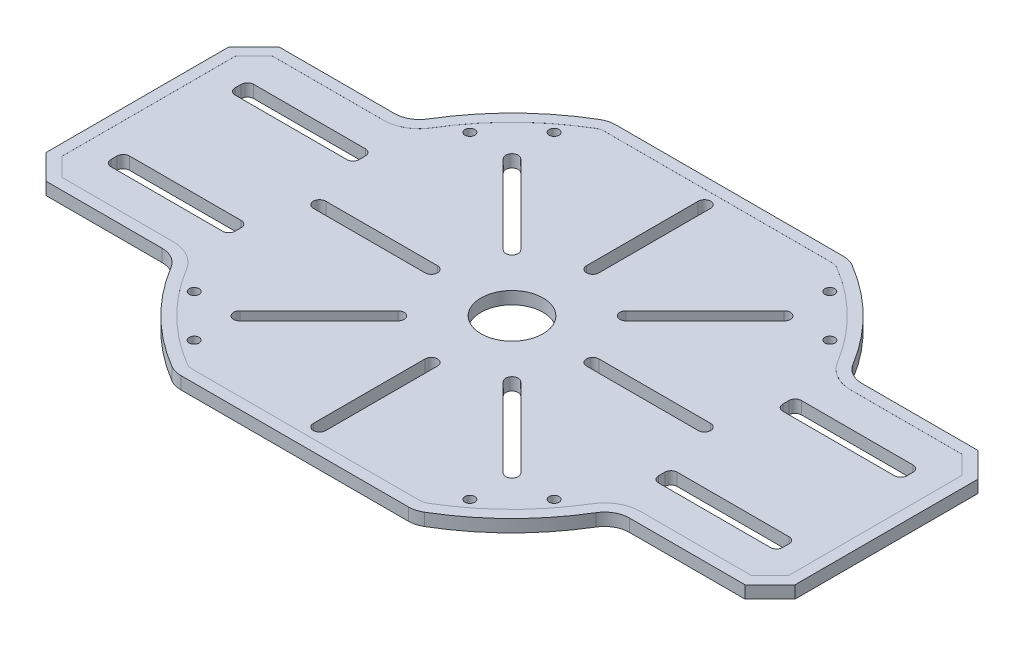
from build123d import *

# Parameters (mm, degrees)
SKETCH1_R           = 6.35
SKETCH1_R_2         = 1.016
SKETCH1_R_3         = 0.080960088
BOSS_EXTRUDE1_DEPTH = 2.54
CUT_EXTRUDE1_DEPTH  = 2.54
CUT_EXTRUDE2_DEPTH  = 2.54
BOSS_EXTRUDE2_DEPTH = 0.01


with BuildPart() as part:
    # Sketch1 → Boss-Extrude1 (new body)
    with BuildSketch(Plane(origin=(0, 0, 0), x_dir=(1, 0, 0), z_dir=(0, 1, 0))):
        with BuildLine():
            Line((-23.244816627, 44.45), (23.244816627, 44.45))
            ThreePointArc((23.244816627, 44.45), (24.583514169, 44.270437622), (25.827574029, 43.744444444))
            ThreePointArc((25.827574029, 43.744444444), (35.740062311, 36.101079569), (43.482663438, 26.265909091))
            ThreePointArc((43.482663438, 26.265909091), (45.334600658, 24.468164919), (47.830929781, 23.8125))
            Line((47.830929781, 23.8125), (71.516875, 23.8125))
            Line((71.516875, 23.8125), (76.596875, 18.7325))
            Line((76.596875, 18.7325), (76.596875, -18.7325))
            Line((76.596875, -18.7325), (71.516875, -23.8125))
            Line((71.516875, -23.8125), (47.830929781, -23.8125))
            ThreePointArc((47.830929781, -23.8125), (45.334600658, -24.468164919), (43.482663438, -26.265909091))
            ThreePointArc((43.482663438, -26.265909091), (35.740062311, -36.101079569), (25.827574029, -43.744444444))
            ThreePointArc((25.827574029, -43.744444444), (24.583514169, -44.270437622), (23.244816627, -44.45))
            Line((23.244816627, -44.45), (-23.244816627, -44.45))
            ThreePointArc((-23.244816627, -44.45), (-24.583514169, -44.270437622), (-25.827574029, -43.744444444))
            ThreePointArc((-25.827574029, -43.744444444), (-35.740062311, -36.101079569), (-43.482663438, -26.265909091))
            ThreePointArc((-43.482663438, -26.265909091), (-45.334600658, -24.468164919), (-47.830929781, -23.8125))
            Line((-47.830929781, -23.8125), (-71.516875, -23.8125))
            Line((-71.516875, -23.8125), (-76.596875, -18.7325))
            Line((-76.596875, -18.7325), (-76.596875, 18.7325))
            Line((-76.596875, 18.7325), (-71.516875, 23.8125))
            Line((-71.516875, 23.8125), (-47.830929781, 23.8125))
            ThreePointArc((-47.830929781, 23.8125), (-45.334600658, 24.468164919), (-43.482663438, 26.265909091))
            ThreePointArc((-43.482663438, 26.265909091), (-35.740062311, 36.101079569), (-25.827574029, 43.744444444))
            ThreePointArc((-25.827574029, 43.744444444), (-24.583514169, 44.270437622), (-23.244816627, 44.45))
        make_face()
        Circle(SKETCH1_R, mode=Mode.SUBTRACT)
        with Locations((36.819050096, 28.19800422)):
            Circle(SKETCH1_R_2, mode=Mode.SUBTRACT)
        with Locations((28.19800422, 36.819050096)):
            Circle(SKETCH1_R_2, mode=Mode.SUBTRACT)
        with Locations((26.671582547, 26.671582547)):
            Circle(SKETCH1_R_3, mode=Mode.SUBTRACT)
        with Locations((26.671582547, -26.671582547)):
            Circle(SKETCH1_R_3, mode=Mode.SUBTRACT)
        with Locations((36.819050096, -28.19800422)):
            Circle(SKETCH1_R_2, mode=Mode.SUBTRACT)
        with Locations((28.19800422, -36.819050096)):
            Circle(SKETCH1_R_2, mode=Mode.SUBTRACT)
        with Locations((-26.671582547, -26.671582547)):
            Circle(SKETCH1_R_3, mode=Mode.SUBTRACT)
        with Locations((-28.19800422, -36.819050096)):
            Circle(SKETCH1_R_2, mode=Mode.SUBTRACT)
        with Locations((-36.819050096, -28.19800422)):
            Circle(SKETCH1_R_2, mode=Mode.SUBTRACT)
        with Locations((-26.671582547, 26.671582547)):
            Circle(SKETCH1_R_3, mode=Mode.SUBTRACT)
        with Locations((-36.819050096, 28.19800422)):
            Circle(SKETCH1_R_2, mode=Mode.SUBTRACT)
        with Locations((-28.19800422, 36.819050096)):
            Circle(SKETCH1_R_2, mode=Mode.SUBTRACT)
    extrude(amount=BOSS_EXTRUDE1_DEPTH)

    # Sketch3 → Cut-Extrude1 (cut)
    with BuildSketch(Plane(origin=(0, 2.54, 0), x_dir=(1, 0, 0), z_dir=(0, 1, 0))):
        with BuildLine():
            Line((10.776307345, 12.572358569), (26.940768363, 28.736819587))
            ThreePointArc((26.940768363, 28.736819587), (28.736819587, 28.736819587), (28.736819587, 26.940768363))
            Line((28.736819587, 26.940768363), (12.572358569, 10.776307345))
            ThreePointArc((12.572358569, 10.776307345), (10.776307345, 10.776307345), (10.776307345, 12.572358569))
        make_face()
        with BuildLine():
            Line((16.51, -1.27), (39.37, -1.27))
            ThreePointArc((39.37, -1.27), (40.64, 0), (39.37, 1.27))
            Line((39.37, 1.27), (16.51, 1.27))
            ThreePointArc((16.51, 1.27), (15.24, 0), (16.51, -1.27))
        make_face()
        with BuildLine():
            Line((10.776307345, -12.572358569), (26.940768363, -28.736819587))
            ThreePointArc((26.940768363, -28.736819587), (28.736819587, -28.736819587), (28.736819587, -26.940768363))
            Line((28.736819587, -26.940768363), (12.572358569, -10.776307345))
            ThreePointArc((12.572358569, -10.776307345), (10.776307345, -10.776307345), (10.776307345, -12.572358569))
        make_face()
        with BuildLine():
            Line((-1.27, -16.51), (-1.27, -39.37))
            ThreePointArc((-1.27, -39.37), (0, -40.64), (1.27, -39.37))
            Line((1.27, -39.37), (1.27, -16.51))
            ThreePointArc((1.27, -16.51), (0, -15.24), (-1.27, -16.51))
        make_face()
        with BuildLine():
            Line((-12.572358569, -10.776307345), (-28.736819587, -26.940768363))
            ThreePointArc((-28.736819587, -26.940768363), (-28.736819587, -28.736819587), (-26.940768363, -28.736819587))
            Line((-26.940768363, -28.736819587), (-10.776307345, -12.572358569))
            ThreePointArc((-10.776307345, -12.572358569), (-10.776307345, -10.776307345), (-12.572358569, -10.776307345))
        make_face()
        with BuildLine():
            Line((-16.51, 1.27), (-39.37, 1.27))
            ThreePointArc((-39.37, 1.27), (-40.64, 0), (-39.37, -1.27))
            Line((-39.37, -1.27), (-16.51, -1.27))
            ThreePointArc((-16.51, -1.27), (-15.24, 0), (-16.51, 1.27))
        make_face()
        with BuildLine():
            Line((-10.776307345, 12.572358569), (-26.940768363, 28.736819587))
            ThreePointArc((-26.940768363, 28.736819587), (-28.736819587, 28.736819587), (-28.736819587, 26.940768363))
            Line((-28.736819587, 26.940768363), (-12.572358569, 10.776307345))
            ThreePointArc((-12.572358569, 10.776307345), (-10.776307345, 10.776307345), (-10.776307345, 12.572358569))
        make_face()
        with BuildLine():
            Line((1.27, 16.51), (1.27, 39.37))
            ThreePointArc((1.27, 39.37), (0, 40.64), (-1.27, 39.37))
            Line((-1.27, 39.37), (-1.27, 16.51))
            ThreePointArc((-1.27, 16.51), (0, 15.24), (1.27, 16.51))
        make_face()
    extrude(amount=-CUT_EXTRUDE1_DEPTH, mode=Mode.SUBTRACT)

    # Sketch4 → Cut-Extrude2 (cut)
    with BuildSketch(Plane(origin=(0, 2.54, 0), x_dir=(1, 0, 0), z_dir=(0, 1, 0))):
        with BuildLine():
            Line((44.592875, 14.605), (67.452875, 14.605))
            ThreePointArc((67.452875, 14.605), (68.350900612, 14.233025612), (68.722875, 13.335))
            Line((68.722875, 13.335), (68.722875, 12.065))
            ThreePointArc((68.722875, 12.065), (68.350900612, 11.166974388), (67.452875, 10.795))
            Line((67.452875, 10.795), (44.592875, 10.795))
            ThreePointArc((44.592875, 10.795), (43.694849388, 11.166974388), (43.322875, 12.065))
            Line((43.322875, 12.065), (43.322875, 13.335))
            ThreePointArc((43.322875, 13.335), (43.694849388, 14.233025612), (44.592875, 14.605))
        make_face()
        with BuildLine():
            Line((68.722875, -13.335), (68.722875, -12.065))
            ThreePointArc((68.722875, -12.065), (68.350900612, -11.166974388), (67.452875, -10.795))
            Line((67.452875, -10.795), (44.592875, -10.795))
            ThreePointArc((44.592875, -10.795), (43.694849388, -11.166974388), (43.322875, -12.065))
            Line((43.322875, -12.065), (43.322875, -13.335))
            ThreePointArc((43.322875, -13.335), (43.694849388, -14.233025612), (44.592875, -14.605))
            Line((44.592875, -14.605), (67.452875, -14.605))
            ThreePointArc((67.452875, -14.605), (68.350900612, -14.233025612), (68.722875, -13.335))
        make_face()
        with BuildLine():
            Line((-44.592875, -14.605), (-67.452875, -14.605))
            ThreePointArc((-67.452875, -14.605), (-68.350900612, -14.233025612), (-68.722875, -13.335))
            Line((-68.722875, -13.335), (-68.722875, -12.065))
            ThreePointArc((-68.722875, -12.065), (-68.350900612, -11.166974388), (-67.452875, -10.795))
            Line((-67.452875, -10.795), (-44.592875, -10.795))
            ThreePointArc((-44.592875, -10.795), (-43.694849388, -11.166974388), (-43.322875, -12.065))
            Line((-43.322875, -12.065), (-43.322875, -13.335))
            ThreePointArc((-43.322875, -13.335), (-43.694849388, -14.233025612), (-44.592875, -14.605))
        make_face()
        with BuildLine():
            Line((-68.722875, 13.335), (-68.722875, 12.065))
            ThreePointArc((-68.722875, 12.065), (-68.350900612, 11.166974388), (-67.452875, 10.795))
            Line((-67.452875, 10.795), (-44.592875, 10.795))
            ThreePointArc((-44.592875, 10.795), (-43.694849388, 11.166974388), (-43.322875, 12.065))
            Line((-43.322875, 12.065), (-43.322875, 13.335))
            ThreePointArc((-43.322875, 13.335), (-43.694849388, 14.233025612), (-44.592875, 14.605))
            Line((-44.592875, 14.605), (-67.452875, 14.605))
            ThreePointArc((-67.452875, 14.605), (-68.350900612, 14.233025612), (-68.722875, 13.335))
        make_face()
    extrude(amount=-CUT_EXTRUDE2_DEPTH, mode=Mode.SUBTRACT)

    # Sketch8 → Boss-Extrude2 (add)
    with BuildSketch(Plane(origin=(0, 2.54, 0), x_dir=(1, 0, 0), z_dir=(0, 1, 0))):
        with BuildLine():
            Line((47.830929781, -23.8125), (71.516875, -23.8125))
            Line((71.516875, -23.8125), (76.596875, -18.7325))
            Line((76.596875, -18.7325), (76.596875, 18.7325))
            Line((76.596875, 18.7325), (71.516875, 23.8125))
            Line((71.516875, 23.8125), (47.830929781, 23.8125))
            ThreePointArc((47.830929781, 23.8125), (45.334600658, 24.468164919), (43.482663438, 26.265909091))
            ThreePointArc((43.482663438, 26.265909091), (35.740062311, 36.101079569), (25.827574029, 43.744444444))
            ThreePointArc((25.827574029, 43.744444444), (24.583514169, 44.270437622), (23.244816627, 44.45))
            Line((23.244816627, 44.45), (-23.244816627, 44.45))
            ThreePointArc((-23.244816627, 44.45), (-24.583514169, 44.270437622), (-25.827574029, 43.744444444))
            ThreePointArc((-25.827574029, 43.744444444), (-35.740062311, 36.101079569), (-43.482663438, 26.265909091))
            ThreePointArc((-43.482663438, 26.265909091), (-45.334600658, 24.468164919), (-47.830929781, 23.8125))
            Line((-47.830929781, 23.8125), (-71.516875, 23.8125))
            Line((-71.516875, 23.8125), (-76.596875, 18.7325))
            Line((-76.596875, 18.7325), (-76.596875, -18.7325))
            Line((-76.596875, -18.7325), (-71.516875, -23.8125))
            Line((-71.516875, -23.8125), (-47.830929781, -23.8125))
            ThreePointArc((-47.830929781, -23.8125), (-45.334600658, -24.468164919), (-43.482663438, -26.265909091))
            ThreePointArc((-43.482663438, -26.265909091), (-35.740062311, -36.101079569), (-25.827574029, -43.744444444))
            ThreePointArc((-25.827574029, -43.744444444), (-24.583514169, -44.270437622), (-23.244816627, -44.45))
            Line((-23.244816627, -44.45), (23.244816627, -44.45))
            ThreePointArc((23.244816627, -44.45), (24.583514169, -44.270437622), (25.827574029, -43.744444444))
            ThreePointArc((25.827574029, -43.744444444), (35.740062311, -36.101079569), (43.482663438, -26.265909091))
            ThreePointArc((43.482663438, -26.265909091), (45.334600658, -24.468164919), (47.830929781, -23.8125))
        make_face()
        with BuildLine():
            Line((47.830929781, -21.5125), (70.564183807, -21.5125))
            Line((70.564183807, -21.5125), (74.296875, -17.779808807))
            Line((74.296875, -17.779808807), (74.296875, 17.779808807))
            Line((74.296875, 17.779808807), (70.564183807, 21.5125))
            Line((70.564183807, 21.5125), (47.830929781, 21.5125))
            ThreePointArc((47.830929781, 21.5125), (44.204372906, 22.465021083), (41.513960172, 25.076704545))
            ThreePointArc((41.513960172, 25.076704545), (34.121909883, 34.466581872), (24.658215363, 41.763888889))
            ThreePointArc((24.658215363, 41.763888889), (23.977410951, 42.051735549), (23.244816627, 42.15))
            Line((23.244816627, 42.15), (-23.244816627, 42.15))
            ThreePointArc((-23.244816627, 42.15), (-23.977410951, 42.051735549), (-24.658215363, 41.763888889))
            ThreePointArc((-24.658215363, 41.763888889), (-34.121909883, 34.466581872), (-41.513960172, 25.076704545))
            ThreePointArc((-41.513960172, 25.076704545), (-44.204372906, 22.465021083), (-47.830929781, 21.5125))
            Line((-47.830929781, 21.5125), (-70.564183807, 21.5125))
            Line((-70.564183807, 21.5125), (-74.296875, 17.779808807))
            Line((-74.296875, 17.779808807), (-74.296875, -17.779808807))
            Line((-74.296875, -17.779808807), (-70.564183807, -21.5125))
            Line((-70.564183807, -21.5125), (-47.830929781, -21.5125))
            ThreePointArc((-47.830929781, -21.5125), (-44.204372906, -22.465021083), (-41.513960172, -25.076704545))
            ThreePointArc((-41.513960172, -25.076704545), (-34.121909883, -34.466581872), (-24.658215363, -41.763888889))
            ThreePointArc((-24.658215363, -41.763888889), (-23.977410951, -42.051735549), (-23.244816627, -42.15))
            Line((-23.244816627, -42.15), (23.244816627, -42.15))
            ThreePointArc((23.244816627, -42.15), (23.977410951, -42.051735549), (24.658215363, -41.763888889))
            ThreePointArc((24.658215363, -41.763888889), (34.121909883, -34.466581872), (41.513960172, -25.076704545))
            ThreePointArc((41.513960172, -25.076704545), (44.204372906, -22.465021083), (47.830929781, -21.5125))
        make_face(mode=Mode.SUBTRACT)
    extrude(amount=BOSS_EXTRUDE2_DEPTH)


solid = part.part
